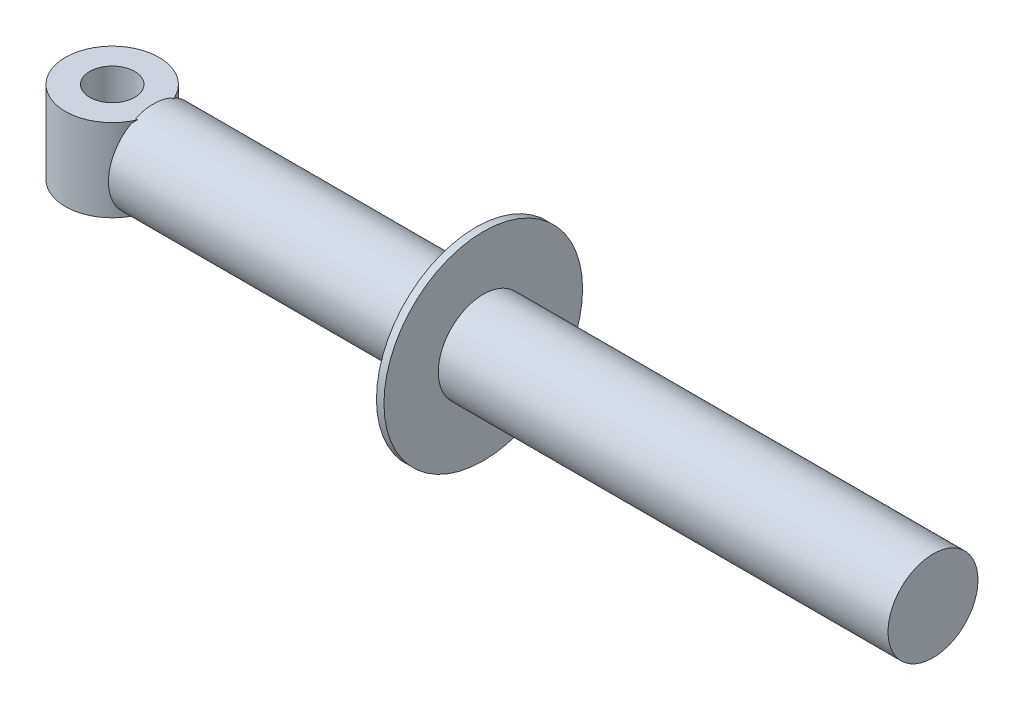
from build123d import *

# Parameters (mm, degrees)
SKETCH2_R           = 12
BOSS_EXTRUDE1_DEPTH = 86
SKETCH3_R           = 12.5
SKETCH3_R_2         = 6
BOSS_EXTRUDE2_DEPTH = 11


with BuildPart() as part:
    # Sketch1 → Revolve1 (revolve)
    with BuildSketch(Plane(origin=(0, 0, 0), x_dir=(1, 0, 0), z_dir=(0, 1, 0))):
        Polygon((0, 0), (0, 26.5), (2, 26.5), (2, 12), (122, 12), (122, 0), align=None)
    revolve(axis=Axis((122, 0, 0), (-1, 0, 0)))

    # Sketch2 → Boss-Extrude1 (add)
    with BuildSketch(Plane.ZY):
        Circle(SKETCH2_R)
    extrude(amount=BOSS_EXTRUDE1_DEPTH)

    # Sketch3 → Boss-Extrude2 (add, symmetric)
    with BuildSketch(Plane(origin=(0, 0, 0), x_dir=(1, 0, 0), z_dir=(0, 1, 0))):
        with Locations((-97, 0)):
            Circle(SKETCH3_R)
        with Locations((-97, 0)):
            Circle(SKETCH3_R_2, mode=Mode.SUBTRACT)
    extrude(amount=BOSS_EXTRUDE2_DEPTH, both=True)


solid = part.part
